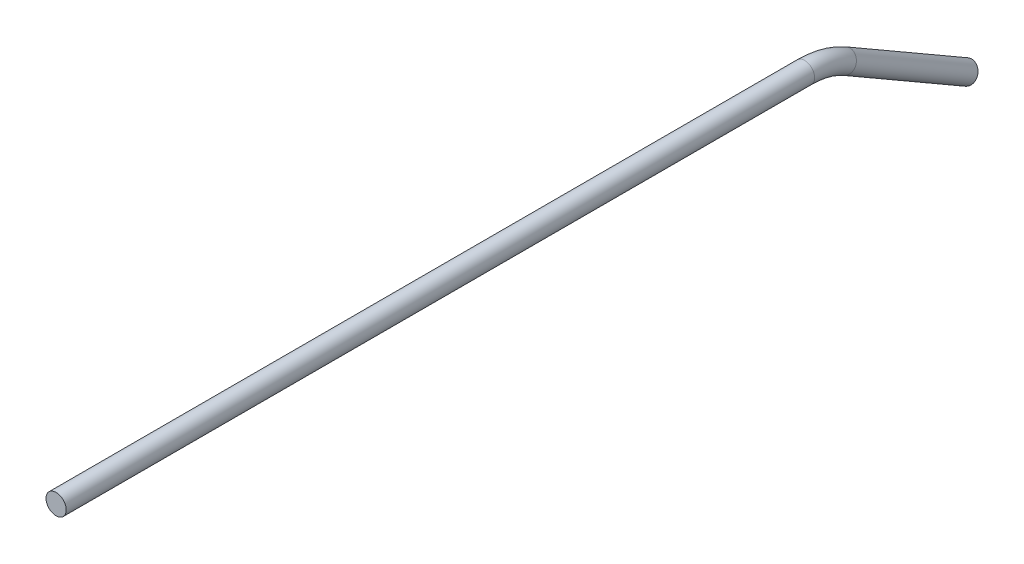
from build123d import *

# Parameters (mm, degrees)
SKETCH2_R = 3.175


with BuildPart() as part:
    # Sweep1: sweep along a path in Sketch4
    with BuildLine(Plane(origin=(0, 0, 0), x_dir=(0, 0, -1), z_dir=(1, 0, 0))) as sweep1_path:
        Line((0, 0), (234.494090512, 0))
        ThreePointArc((234.494090512, 0), (241.068094258, -0.865484012), (247.194090512, -3.402954744))
        Line((247.194090512, -3.402954744), (285.294090512, -25.4))
    # Sketch2 → Sweep1 (sweep)
    with BuildSketch(Plane.XY):
        Circle(SKETCH2_R)
    sweep(path=sweep1_path.line)


solid = part.part
